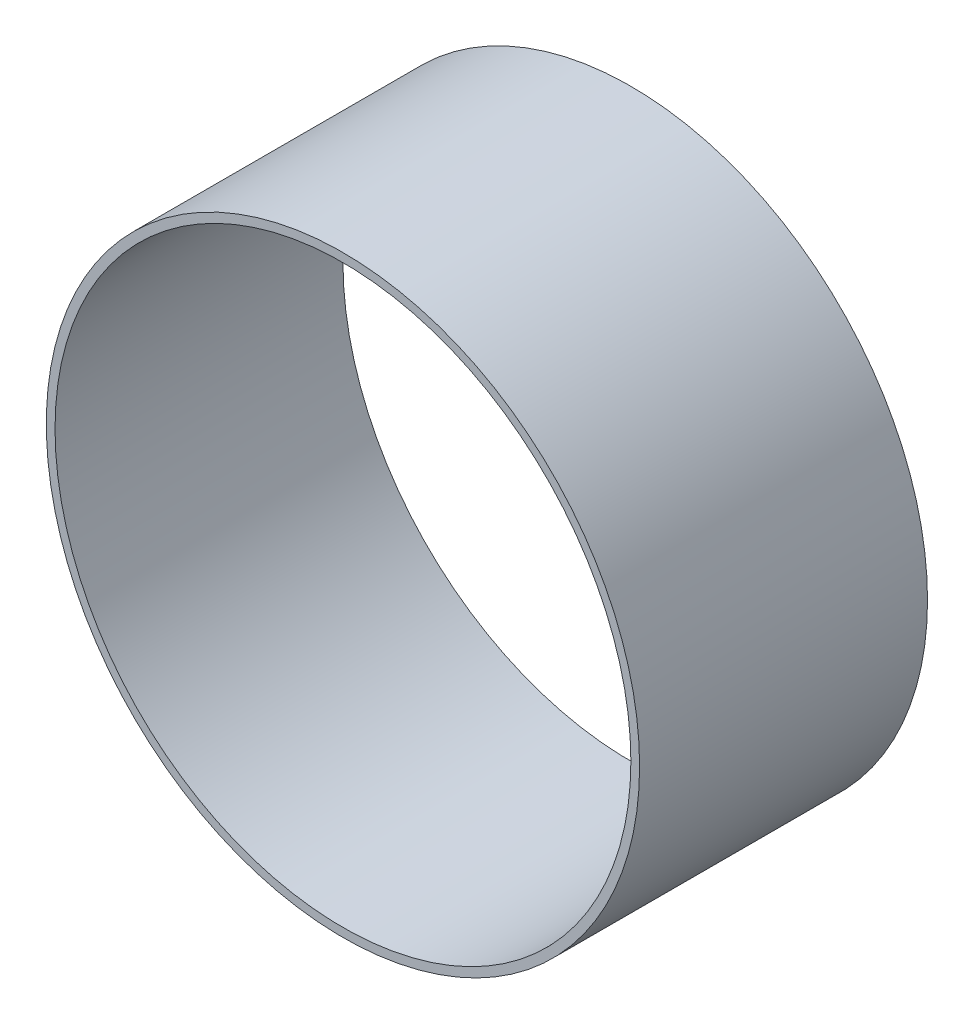
from build123d import *

# Parameters (mm, degrees)
SKETCH1_R           = 39.2557
SKETCH1_R_2         = 38.1
BOSS_EXTRUDE1_DEPTH = 19.05


with BuildPart() as part:
    # Sketch1 → Boss-Extrude1 (new body, symmetric)
    with BuildSketch(Plane.XY):
        Circle(SKETCH1_R)
        Circle(SKETCH1_R_2, mode=Mode.SUBTRACT)
    extrude(amount=BOSS_EXTRUDE1_DEPTH, both=True)


solid = part.part
